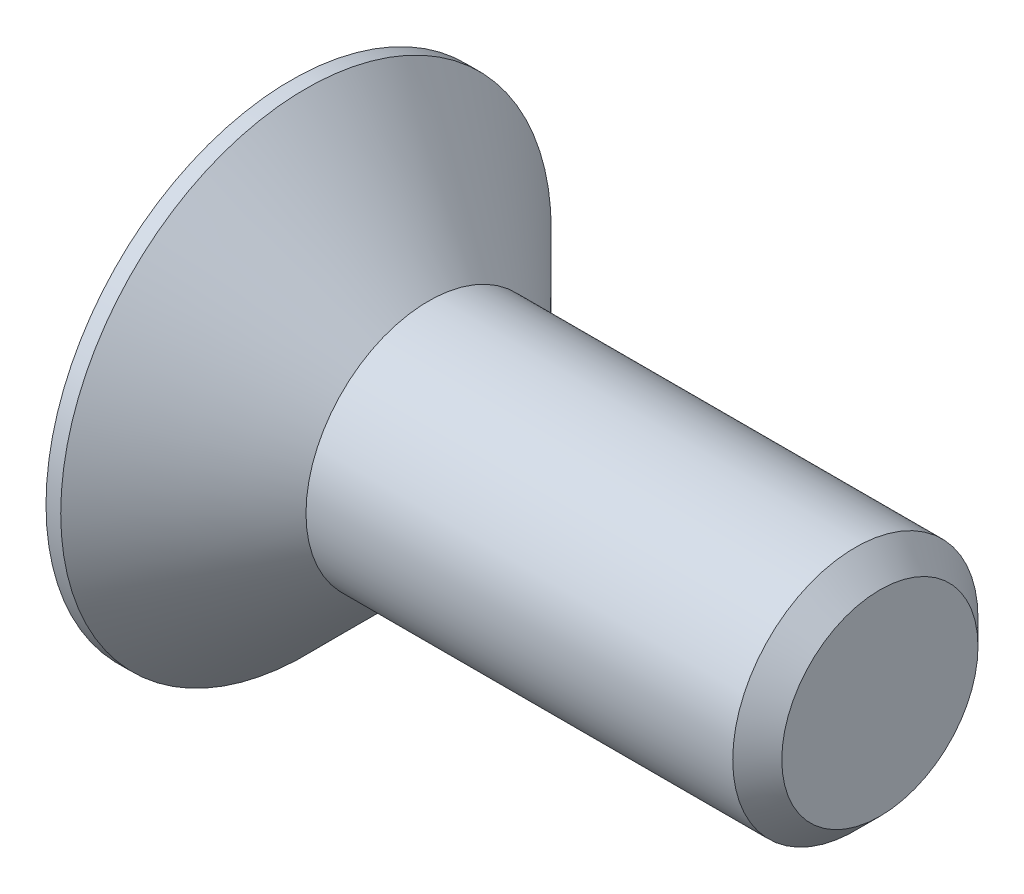
from build123d import *

# Parameters (mm, degrees)
CUT_EXTRUDE1_DEPTH = 0.8


with BuildPart() as part:
    # Sketch2 → Revolve1 (revolve)
    with BuildSketch(Plane.XY):
        Polygon((0, 0), (0, 2.5), (0.15, 2.5), (1.4, 1.25), (5.75, 1.25), (6, 1), (6, 0), align=None)
    revolve(axis=Axis((-2.281841559, 0, 0), (1, 0, 0)))

    # Sketch3 → Cut-Extrude1 (cut)
    with BuildSketch(Plane.ZY):
        Polygon((0.433012702, -0.75), (0.866025404, 0), (0.433012702, 0.75), (-0.433012702, 0.75), (-0.866025404, 0), (-0.433012702, -0.75), align=None)
    extrude(amount=-CUT_EXTRUDE1_DEPTH, mode=Mode.SUBTRACT)


solid = part.part
